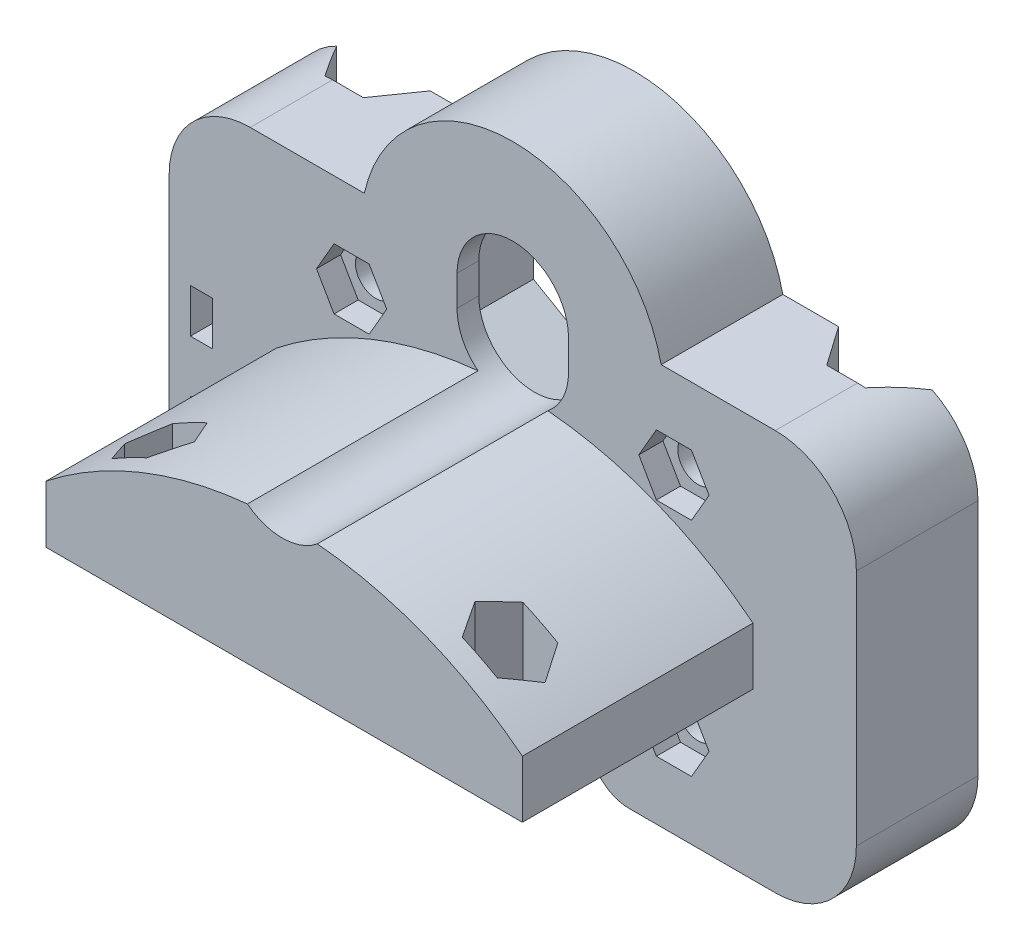
from build123d import *

# Parameters (mm, degrees)
SKETCH1_R               = 2
BOSS_EXTRUDE4_DEPTH     = 34.75
SKETCH5_R               = 2
CUT_EXTRUDE2_DEPTH      = 22.75
CUT_EXTRUDE3_REACH      = 59.871
CUT_EXTRUDE4_DEPTH      = 63.586120666
CUT_EXTRUDE5_REACH      = 61.819
CUT_EXTRUDE5_END_RADIUS = 37.906002519
SKETCH10_R              = 1.8
CUT_EXTRUDE6_REACH      = 59.074
SKETCH11_RX             = 1.8
SKETCH11_RY             = 1.799979565
CUT_EXTRUDE7_REACH      = 59.075
SKETCH11_4_RX           = 1.8
SKETCH11_4_RY           = 1.799979565
CUT_EXTRUDE8_DEPTH      = 9.85
SKETCH15_R              = 2
CUT_EXTRUDE9_DEPTH      = 2.38
SKETCH16_R              = 1.25
CUT_EXTRUDE10_DEPTH     = 6.1
SKETCH17_W              = 2.2
SKETCH17_H              = 4.33
CUT_EXTRUDE11_DEPTH     = 6.55
BOSS_EXTRUDE5_DEPTH     = 2.2
BOSS_EXTRUDE6_DEPTH     = 2.2


with BuildPart() as part:
    # Sketch1 → Boss-Extrude4 (new body)
    with BuildSketch(Plane.XY):
        with BuildLine():
            Line((-25.9, -19.75), (-11.5, -19.75))
            ThreePointArc((-11.5, -19.75), (-8.671572875, -18.578427125), (-7.5, -15.75))
            Line((-7.5, -15.75), (-7.5, -13))
            ThreePointArc((-7.5, -13), (0, -5.5), (7.5, -13))
            Line((7.5, -13), (7.5, -15.75))
            ThreePointArc((7.5, -15.75), (8.671572875, -18.578427125), (11.5, -19.75))
            Line((11.5, -19.75), (25.9, -19.75))
            ThreePointArc((25.9, -19.75), (31.556854249, -17.406854249), (33.9, -11.75))
            Line((33.9, -11.75), (33.9, 11.75))
            ThreePointArc((33.9, 11.75), (31.556854249, 17.406854249), (25.9, 19.75))
            Line((25.9, 19.75), (14.643684646, 19.75))
            ThreePointArc((14.643684646, 19.75), (0, 31.5), (-14.643684646, 19.75))
            Line((-14.643684646, 19.75), (-25.9, 19.75))
            ThreePointArc((-25.9, 19.75), (-31.556854249, 17.406854249), (-33.9, 11.75))
            Line((-33.9, 11.75), (-33.9, -11.75))
            ThreePointArc((-33.9, -11.75), (-31.556854249, -17.406854249), (-25.9, -19.75))
        make_face()
        with Locations((-15.9, 10.944699181)):
            Circle(SKETCH1_R, mode=Mode.SUBTRACT)
        with Locations(Location((-15.9, -10.944699181, 0), (0, 0, 180))):
            Circle(SKETCH1_R, mode=Mode.SUBTRACT)
        with Locations((15.9, -10.944699181)):
            Circle(SKETCH1_R, mode=Mode.SUBTRACT)
        with Locations(Location((15.9, 10.944699181, 0), (0, 0, 180))):
            Circle(SKETCH1_R, mode=Mode.SUBTRACT)
    extrude(amount=BOSS_EXTRUDE4_DEPTH)

    # Sketch5 → Cut-Extrude2 (cut)
    with BuildSketch(Plane.XY.offset(34.75)):
        with BuildLine():
            Line((33.9, -11.75), (33.9, 11.75))
            ThreePointArc((33.9, 11.75), (31.556854249, 17.406854249), (25.9, 19.75))
            Line((25.9, 19.75), (14.643684646, 19.75))
            ThreePointArc((14.643684646, 19.75), (0, 31.5), (-14.643684646, 19.75))
            Line((-14.643684646, 19.75), (-25.9, 19.75))
            ThreePointArc((-25.9, 19.75), (-31.556854249, 17.406854249), (-33.9, 11.75))
            Line((-33.9, 11.75), (-33.9, -11.75))
            ThreePointArc((-33.9, -11.75), (-31.556854249, -17.406854249), (-25.9, -19.75))
            Line((-25.9, -19.75), (-11.5, -19.75))
            ThreePointArc((-11.5, -19.75), (-8.671572875, -18.578427125), (-7.5, -15.75))
            Line((-7.5, -15.75), (-7.5, -13))
            ThreePointArc((-7.5, -13), (0, -5.5), (7.5, -13))
            Line((7.5, -13), (7.5, -15.75))
            ThreePointArc((7.5, -15.75), (8.671572875, -18.578427125), (11.5, -19.75))
            Line((11.5, -19.75), (25.9, -19.75))
            ThreePointArc((25.9, -19.75), (31.556854249, -17.406854249), (33.9, -11.75))
        make_face()
        with Locations((-15.9, 10.944699181)):
            Circle(SKETCH5_R, mode=Mode.SUBTRACT)
        with BuildLine():
            Line((-23.3, -3.45), (-23.3, 2.199999619))
            ThreePointArc((-23.3, 2.199999619), (0.199916465, 10.363760615), (23.699998093, 2.200475068))
            Line((23.699998093, 2.200475068), (23.699998093, -3.45))
            Line((23.699998093, -3.45), (-23.3, -3.45))
        make_face(mode=Mode.SUBTRACT)
    extrude(amount=-CUT_EXTRUDE2_DEPTH, mode=Mode.SUBTRACT)

    # Sketch6 → Cut-Extrude3 (cut, up to next)
    with BuildSketch(Plane.XY.offset(34.75), mode=Mode.PRIVATE) as cut_extrude3_sk1:
        with BuildLine():
            Line((-5.499999046, 14.493093188), (-5.499999046, 17.489830849))
            ThreePointArc((-5.499999046, 17.489830849), (0, 22.989829895), (5.499999046, 17.489830849))
            Line((5.499999046, 17.489830849), (5.499999046, 14.493093188))
            ThreePointArc((5.499999046, 14.493093188), (0, 8.993094142), (-5.499999046, 14.493093188))
        make_face()
    cut_extrude3_tool1 = extrude(cut_extrude3_sk1.sketch, amount=-CUT_EXTRUDE3_REACH, mode=Mode.PRIVATE) & part.part
    add(cut_extrude3_tool1.solids().sort_by_distance((0, 15.991462, 34.75))[0], mode=Mode.SUBTRACT)

    # Sketch9 → Cut-Extrude4 (cut, through all)
    with BuildSketch(Plane(origin=(0, 19.75, 0), x_dir=(1, 0, 0), z_dir=(0, 1, 0))):
        Polygon((-29.366805248, 0), (-26.65, -3.88), (-22.86, -3.88), (-20.143194752, 0), align=None)
        Polygon((22.86, -3.88), (20.143194752, 0), (29.366805248, 0), (26.65, -3.88), align=None)
    extrude(amount=-CUT_EXTRUDE4_DEPTH, mode=Mode.SUBTRACT)

    # Cut-Extrude5: up to this cylinder (the profile starts inside it)
    cut_extrude5_end = Plane(origin=(0.20029992, -27.542241902, 29.5), z_dir=(0, 0, 1)) * Cylinder(CUT_EXTRUDE5_END_RADIUS, 200.450005039, mode=Mode.PRIVATE)
    # Sketch10 → Cut-Extrude5 (cut, up to the surface)
    with BuildSketch(Plane.XZ.offset(3.45), mode=Mode.PRIVATE) as cut_extrude5_sk1:
        with Locations((-17.3, 29.5)):
            Circle(SKETCH10_R)
    cut_extrude5_tool1 = extrude(cut_extrude5_sk1.sketch, amount=-CUT_EXTRUDE5_REACH, mode=Mode.PRIVATE) & cut_extrude5_end
    add(cut_extrude5_tool1.solids().sort_by_distance((-17.3, -3.45, 29.5))[0], mode=Mode.SUBTRACT)
    # Sketch10 → Cut-Extrude5 (cut, up to the surface)
    with BuildSketch(Plane.XZ.offset(3.45), mode=Mode.PRIVATE) as cut_extrude5_sk2:
        with Locations((17.3, 29.5)):
            Circle(SKETCH10_R)
    cut_extrude5_tool2 = extrude(cut_extrude5_sk2.sketch, amount=-CUT_EXTRUDE5_REACH, mode=Mode.PRIVATE) & cut_extrude5_end
    add(cut_extrude5_tool2.solids().sort_by_distance((17.3, -3.45, 29.5))[0], mode=Mode.SUBTRACT)

    # Cut-Extrude6: up to this plane
    cut_extrude6_end = Plane(origin=(0, -1.1, 12), z_dir=(0, 1, 0))
    # Sketch11 → Cut-Extrude6 (cut, up to the surface)
    with BuildSketch(Plane(origin=(-0.04863224, 10.206057531, 0), x_dir=(-0.999988647405363, -0.004764982727443531, 0), z_dir=(0.00476498272744353, -0.9999886474053629, 0)), mode=Mode.PRIVATE) as cut_extrude6_sk1:
        Polygon((13.863688181, -29.5), (15.589965486, -32.49), (19.042520095, -32.49), (20.7687974, -29.5), (19.042520095, -26.51), (15.589965486, -26.51), align=None)
        with Locations(Location((17.316242791, -29.5), (0, 0, -90))):
            Ellipse(SKETCH11_RX, SKETCH11_RY, mode=Mode.SUBTRACT)
    cut_extrude6_tool1 = split(extrude(cut_extrude6_sk1.sketch, amount=CUT_EXTRUDE6_REACH, mode=Mode.PRIVATE), bisect_by=cut_extrude6_end, keep=Keep.BOTH, mode=Mode.PRIVATE)
    add(cut_extrude6_tool1.solids().sort_by_distance((-14.854399, 10.135508, 30.949327))[0], mode=Mode.SUBTRACT)
    # Sketch11 → Cut-Extrude6 (cut, up to the surface)
    with BuildSketch(Plane(origin=(-0.04863224, 10.206057531, 0), x_dir=(-0.999988647405363, -0.004764982727443531, 0), z_dir=(0.00476498272744353, -0.9999886474053629, 0)), mode=Mode.PRIVATE) as cut_extrude6_sk2:
        with Locations(Location((17.316242791, -29.5), (0, 0, -90))):
            Ellipse(SKETCH11_RX, SKETCH11_RY)
    cut_extrude6_tool2 = split(extrude(cut_extrude6_sk2.sketch, amount=CUT_EXTRUDE6_REACH, mode=Mode.PRIVATE), bisect_by=cut_extrude6_end, keep=Keep.BOTH, mode=Mode.PRIVATE)
    add(cut_extrude6_tool2.solids().sort_by_distance((-17.364678, 10.123546, 29.5))[0], mode=Mode.SUBTRACT)

    # Cut-Extrude7: up to this plane
    cut_extrude7_end = Plane(origin=(0, -1.1, 12), z_dir=(0, 1, 0))
    # Sketch11_4 → Cut-Extrude7 (cut, up to the surface)
    with BuildSketch(Plane(origin=(-0.04863224, 10.206057531, 0), x_dir=(-0.999988647405363, -0.004764982727443531, 0), z_dir=(0.00476498272744353, -0.9999886474053629, 0)), mode=Mode.PRIVATE) as cut_extrude7_sk1:
        Polygon((-13.8308098, -29.5), (-15.557087105, -26.51), (-19.009641715, -26.51), (-20.735919019, -29.5), (-19.009641715, -32.49), (-15.557087105, -32.49), align=None)
        with Locations(Location((-17.28336441, -29.5), (0, 0, -90))):
            Ellipse(SKETCH11_4_RX, SKETCH11_4_RY, mode=Mode.SUBTRACT)
    cut_extrude7_tool1 = split(extrude(cut_extrude7_sk1.sketch, amount=CUT_EXTRUDE7_REACH, dir=(0, -1, 0), mode=Mode.PRIVATE), bisect_by=cut_extrude7_end, keep=Keep.BOTH, mode=Mode.PRIVATE)
    add(cut_extrude7_tool1.solids().sort_by_distance((14.724256, 10.276451, 28.050673))[0], mode=Mode.SUBTRACT)
    # Sketch11_4 → Cut-Extrude7 (cut, up to the surface)
    with BuildSketch(Plane(origin=(-0.04863224, 10.206057531, 0), x_dir=(-0.999988647405363, -0.004764982727443531, 0), z_dir=(0.00476498272744353, -0.9999886474053629, 0)), mode=Mode.PRIVATE) as cut_extrude7_sk2:
        with Locations(Location((-17.28336441, -29.5), (0, 0, -90))):
            Ellipse(SKETCH11_4_RX, SKETCH11_4_RY)
    cut_extrude7_tool2 = split(extrude(cut_extrude7_sk2.sketch, amount=CUT_EXTRUDE7_REACH, dir=(0, -1, 0), mode=Mode.PRIVATE), bisect_by=cut_extrude7_end, keep=Keep.BOTH, mode=Mode.PRIVATE)
    add(cut_extrude7_tool2.solids().sort_by_distance((17.234536, 10.288412, 29.5))[0], mode=Mode.SUBTRACT)

    # Sketch14 → Cut-Extrude8 (cut)
    with BuildSketch(Plane(origin=(0, 0, 0), x_dir=(-1, 0, 0), z_dir=(0, 0, -1))):
        Polygon((0, 3), (9.959292144, 8.75), (9.959292144, 23.25), (0, 29), (-9.959292144, 23.25), (-9.959292144, 8.75), align=None)
    extrude(amount=-CUT_EXTRUDE8_DEPTH, mode=Mode.SUBTRACT)

    # Sketch15 → Cut-Extrude9 (cut)
    with BuildSketch(Plane.XY.offset(12)):
        Polygon((-14.167949192, 7.944699181), (-12.435898385, 10.944699181), (-14.167949192, 13.944699181), (-17.632050808, 13.944699181), (-19.364101615, 10.944699181), (-17.632050808, 7.944699181), align=None)
        with Locations((-15.9, 10.944699181)):
            Circle(SKETCH15_R, mode=Mode.SUBTRACT)
        with Locations((-15.9, 10.944699181)):
            Circle(SKETCH15_R)
        Polygon((14.167949192, 13.944699181), (17.632050808, 13.944699181), (19.364101615, 10.944699181), (17.632050808, 7.944699181), (14.167949192, 7.944699181), (12.435898385, 10.944699181), align=None)
        with Locations(Location((15.9, 10.944699181, 0), (0, 0, 180))):
            Circle(SKETCH15_R, mode=Mode.SUBTRACT)
        with Locations(Location((15.9, 10.944699181, 0), (0, 0, 180))):
            Circle(SKETCH15_R)
        Polygon((12.435898385, -10.944699181), (14.167949192, -13.944699181), (17.632050808, -13.944699181), (19.364101615, -10.944699181), (17.632050808, -7.944699181), (14.167949192, -7.944699181), align=None)
        with Locations((15.9, -10.944699181)):
            Circle(SKETCH15_R, mode=Mode.SUBTRACT)
        with Locations((15.9, -10.944699181)):
            Circle(SKETCH15_R)
        Polygon((-17.632050808, -13.944699181), (-19.364101615, -10.944699181), (-17.632050808, -7.944699181), (-14.167949192, -7.944699181), (-12.435898385, -10.944699181), (-14.167949192, -13.944699181), align=None)
        with Locations(Location((-15.9, -10.944699181, 0), (0, 0, 180))):
            Circle(SKETCH15_R, mode=Mode.SUBTRACT)
        with Locations(Location((-15.9, -10.944699181, 0), (0, 0, 180))):
            Circle(SKETCH15_R)
    extrude(amount=-CUT_EXTRUDE9_DEPTH, mode=Mode.SUBTRACT)

    # Sketch16 → Cut-Extrude10 (cut)
    with BuildSketch(Plane.ZY.offset(33.9)):
        with Locations((8.05, 1.13)):
            Circle(SKETCH16_R)
        with Locations((8.05, -8.33)):
            Circle(SKETCH16_R)
    extrude(amount=-CUT_EXTRUDE10_DEPTH, mode=Mode.SUBTRACT)

    # Sketch17 → Cut-Extrude11 (cut)
    with BuildSketch(Plane.XY.offset(12)):
        with Locations((-30.7, 1.13)):
            Rectangle(SKETCH17_W, SKETCH17_H)
        with Locations((-30.7, -8.33)):
            Rectangle(SKETCH17_W, SKETCH17_H)
    extrude(amount=-CUT_EXTRUDE11_DEPTH, mode=Mode.SUBTRACT)

    # Sketch18 → Boss-Extrude5 (add)
    with BuildSketch(Plane.ZY.offset(29.6)):
        Polygon((5.45, 3.295), (5.45, 1.13), (6.699963333, 3.295), align=None)
        Polygon((5.45, -1.035), (6.699963333, -1.035), (5.45, 1.13), align=None)
    extrude(amount=BOSS_EXTRUDE5_DEPTH)

    # Sketch21 → Boss-Extrude6 (add)
    with BuildSketch(Plane(origin=(-31.8, 0, 0), x_dir=(0, 0, -1), z_dir=(1, 0, 0))):
        Polygon((-5.45, -6.165), (-6.699963333, -6.165), (-5.45, -8.33), align=None)
        Polygon((-5.45, -10.495), (-5.45, -8.33), (-6.699963333, -10.495), align=None)
    extrude(amount=BOSS_EXTRUDE6_DEPTH)


solid = part.part
